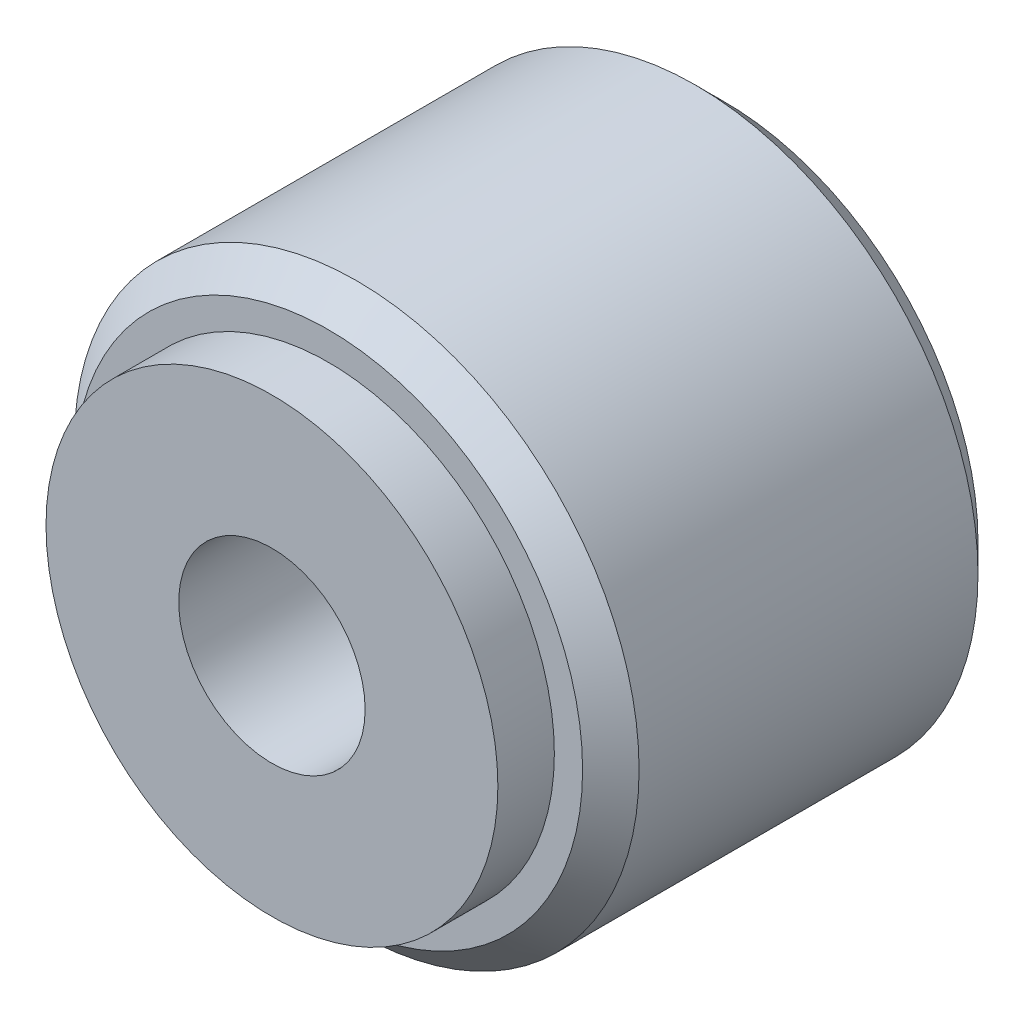
from build123d import *

# Parameters (mm, degrees)
SKETCH_1_R      = 5
EXTRUDE_1_DEPTH = 7
SKETCH_2_R      = 4
EXTRUDE_2_DEPTH = 1
M4X0_71_D       = 3.3
M4X0_71_DEPTH   = 5.8
M4X0_71_TIP     = 0.991420021
CHAMFER_1_SIZE  = 0.5


with BuildPart() as part:
    # Эскиз1 → Бобышка-Вытянуть1 (new body)
    with BuildSketch(Plane.XY):
        Circle(SKETCH_1_R)
    extrude(amount=EXTRUDE_1_DEPTH)

    # Эскиз2 → Бобышка-Вытянуть2 (add)
    with BuildSketch(Plane.XY.offset(7)):
        Circle(SKETCH_2_R)
    extrude(amount=EXTRUDE_2_DEPTH)

    # Отверстие обработанное метчиком M4x0.71
    with Locations(Plane.XY.offset(8)):
        with Locations((0, 0)):
            Hole(M4X0_71_D / 2, depth=M4X0_71_DEPTH)
            with Locations((0, 0, -(M4X0_71_DEPTH + M4X0_71_TIP / 2))):  # 118° drill point
                Cone(0, M4X0_71_D / 2, M4X0_71_TIP, mode=Mode.SUBTRACT)

    # Фаска1
    chamfer_1_edges = [part.edges().sort_by_distance(p)[0] for p in [
        (-5, 0, 0),
        (-5, 0, 7),
    ]]
    chamfer(chamfer_1_edges, length=CHAMFER_1_SIZE)


solid = part.part
